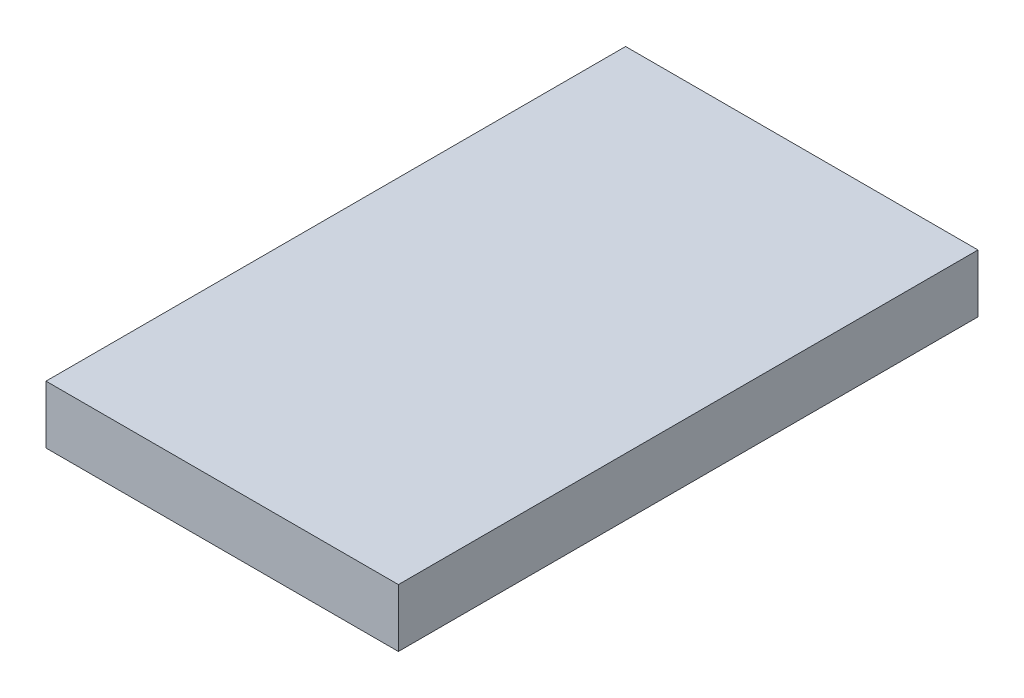
from build123d import *

# Parameters (mm, degrees)
SKIZZE1_W                       = 6.08
SKIZZE1_H                       = 1
AUFSATZ_LINEAR_AUSTRAGEN1_DEPTH = 10


with BuildPart() as part:
    # Skizze1 → Aufsatz-Linear austragen1 (new body)
    with BuildSketch(Plane.XY):
        with Locations((-223.265, -16.525)):
            Rectangle(SKIZZE1_W, SKIZZE1_H)
    extrude(amount=AUFSATZ_LINEAR_AUSTRAGEN1_DEPTH)


solid = part.part
